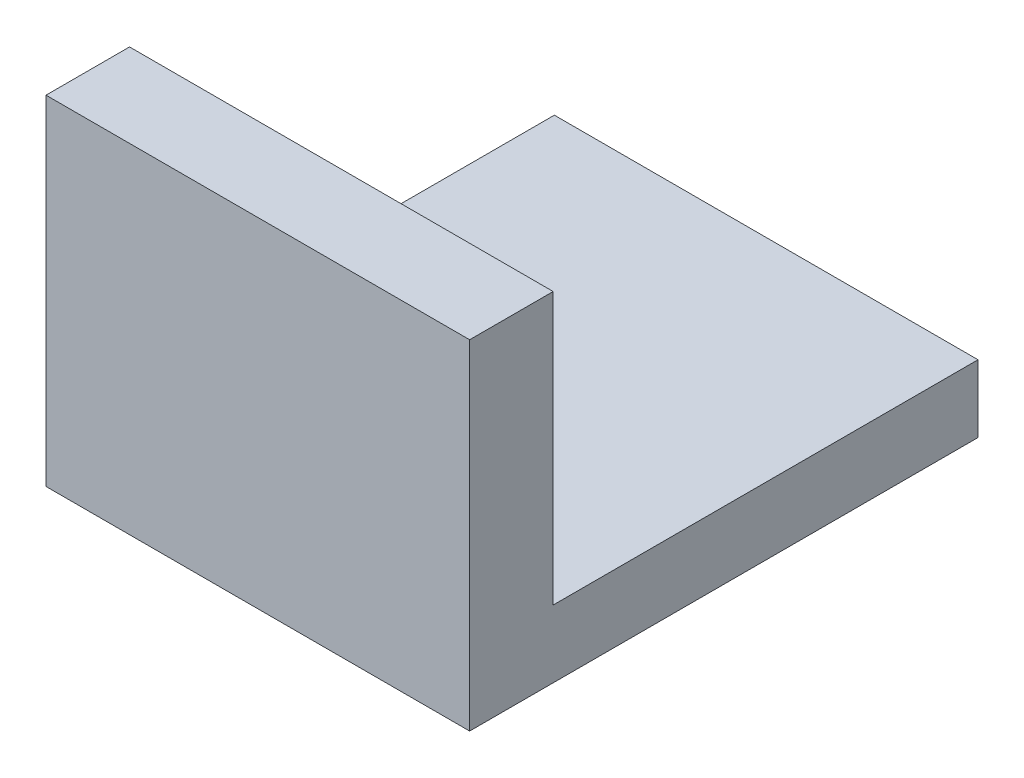
from build123d import *

# Parameters (mm, degrees)
BOSS_EXTRUDE1_DEPTH = 127


with BuildPart() as part:
    # Sketch2 → Boss-Extrude1 (new body)
    with BuildSketch(Plane(origin=(0, 0, 0), x_dir=(0, 0, -1), z_dir=(1, 0, 0))):
        Polygon((0, 0), (0, 101.6), (25.04461424, 101.6), (25.04461424, 20.206399516), (152.4, 20.206399516), (152.4, 0), align=None)
    extrude(amount=BOSS_EXTRUDE1_DEPTH)


solid = part.part
